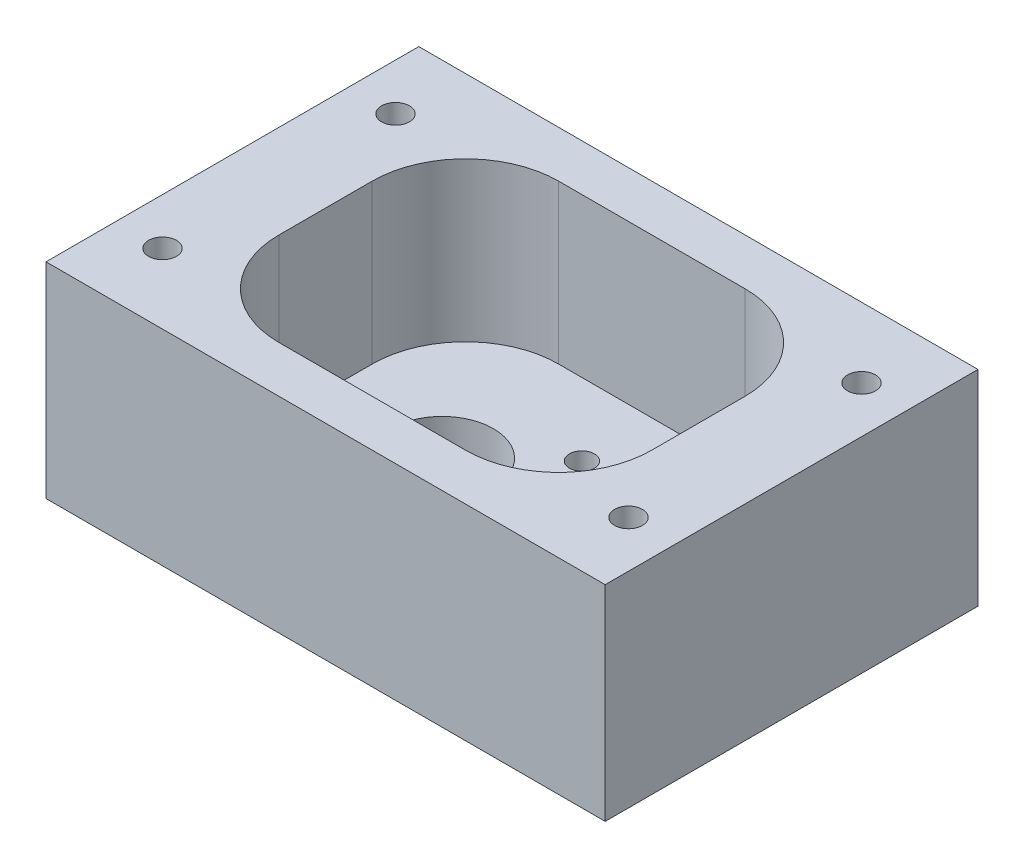
from build123d import *

# Parameters (mm, degrees)
SKETCH1_W             = 76.2
SKETCH1_H             = 50.8
BOSS_EXTRUDE1_DEPTH   = 27.94
SKETCH2_R             = 6.985
SKETCH2_R_2           = 9
CUT_EXTRUDE1_DEPTH    = 28.94
CUT_EXTRUDE2_DEPTH    = 21.59
M3_CLEARANCE_HOLE1_D  = 3.4
F_6_CLEARANCE_HOLE1_D = 3.7973


with BuildPart() as part:
    # Sketch1 → Boss-Extrude1 (new body)
    with BuildSketch(Plane(origin=(0, 0, 0), x_dir=(1, 0, 0), z_dir=(0, 1, 0))):
        Rectangle(SKETCH1_W, SKETCH1_H)
    extrude(amount=BOSS_EXTRUDE1_DEPTH)

    # Sketch2 → Cut-Extrude1 (cut, through all)
    with BuildSketch(Plane.XZ):
        with Locations((-9.525, 0)):
            Circle(SKETCH2_R)
        with Locations((9.525, 0)):
            Circle(SKETCH2_R_2)
    extrude(amount=-CUT_EXTRUDE1_DEPTH, mode=Mode.SUBTRACT)

    # Sketch3 → Cut-Extrude2 (cut)
    with BuildSketch(Plane(origin=(0, 27.94, 0), x_dir=(1, 0, 0), z_dir=(0, 1, 0))):
        with BuildLine():
            Line((-12.7, -19.05), (12.7, -19.05))
            ThreePointArc((12.7, -19.05), (21.680256121, -15.330256121), (25.4, -6.35))
            Line((25.4, -6.35), (25.4, 6.35))
            ThreePointArc((25.4, 6.35), (21.680256121, 15.330256121), (12.7, 19.05))
            Line((12.7, 19.05), (-12.7, 19.05))
            ThreePointArc((-12.7, 19.05), (-21.680256121, 15.330256121), (-25.4, 6.35))
            Line((-25.4, 6.35), (-25.4, -6.35))
            ThreePointArc((-25.4, -6.35), (-21.680256121, -15.330256121), (-12.7, -19.05))
        make_face()
    extrude(amount=-CUT_EXTRUDE2_DEPTH, mode=Mode.SUBTRACT)

    # M3 Clearance Hole1 (through all)
    with Locations(Plane(origin=(0.332611845, 0, 9.192388155), x_dir=(0, 0, -1), z_dir=(0, -1, 0))):
        with Locations((0, 0), (18.38477631, 0), (0, 18.38477631), (18.38477631, 18.38477631)):
            Hole(M3_CLEARANCE_HOLE1_D / 2)

    # #6 Clearance Hole1 (through all)
    with Locations(Plane(origin=(-31.75, 0, 15.875), x_dir=(0, 0, -1), z_dir=(0, -1, 0))):
        with Locations((0, 0), (31.75, 0), (0, 63.5), (31.75, 63.5)):
            Hole(F_6_CLEARANCE_HOLE1_D / 2)


solid = part.part
